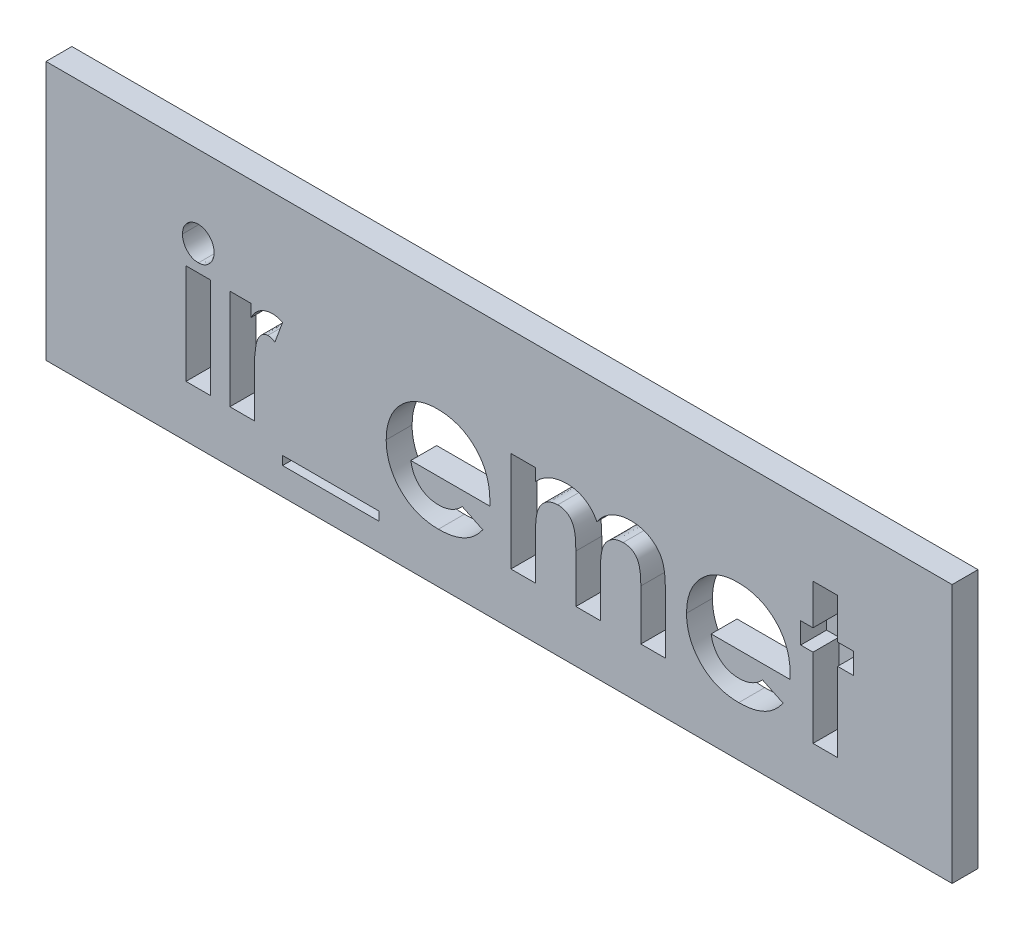
from build123d import *

# Parameters (mm, degrees)
ESQUISSE1_W             = 35
ESQUISSE1_H             = 10
BOSS_EXTRU_1_DEPTH      = 1
ESQUISSE2_R             = 1
BOSS_EXTRU_2_DEPTH      = 3
CHANFREIN1_SIZE         = 0.5
ESQUISSE3_W             = 0.949786325
ESQUISSE3_H             = 3.866987179
ESQUISSE3_W_2           = 3.731303419
ESQUISSE3_H_2           = 0.339209402
ENL_V_MAT_EXTRU_2_DEPTH = 1


with BuildPart() as part:
    # Esquisse1 → Boss.-Extru.1 (new body)
    with BuildSketch(Plane.XY):
        with Locations((17.5, -5)):
            Rectangle(ESQUISSE1_W, ESQUISSE1_H)
    extrude(amount=BOSS_EXTRU_1_DEPTH)

    # Esquisse2 → Boss.-Extru.2 (add)
    with BuildSketch(Plane(origin=(0, 0, 0), x_dir=(-1, 0, 0), z_dir=(0, 0, -1))):
        with Locations(Location((-30, -5, 0), (0, 0, 180))):  # turned: the seam where the file's is
            Circle(ESQUISSE2_R)
        with Locations(Location((-5, -5, 0), (0, 0, 180))):  # turned: the seam where the file's is
            Circle(ESQUISSE2_R)
    extrude(amount=BOSS_EXTRU_2_DEPTH)

    # Chanfrein1
    chanfrein1_edges = [part.edges().sort_by_distance(p)[0] for p in [
        (29, -5, -3),
        (4, -5, -3),
    ]]
    chamfer(chanfrein1_edges, length=CHANFREIN1_SIZE)

    # Esquisse3 → Enlèv. mat.-Extru.2 (cut)
    with BuildSketch(Plane.XY.offset(1)):
        with BuildLine():
            add(Edge.make_bspline(
                [(5.879824386, -2.504807692), (5.92076017, -2.506816157), (6.001141525, -2.51075997), (6.116298756, -2.549203379), (6.221989755, -2.609539161), (6.315423529, -2.692321292), (6.393133006, -2.791178297), (6.452505932, -2.901855287), (6.485580115, -3.024481827), (6.49017363, -3.109190958), (6.492521368, -3.152485644)],
                knots=[0, 0, 0, 0, 0.989868614, 1.943702388, 2.910836514, 3.924849579, 4.949916355, 5.946401046, 6.950409252, 8, 8, 8, 8], degree=3))
            add(Edge.make_bspline(
                [(6.492521368, -3.152485644), (6.490257628, -3.195461271), (6.485846625, -3.279201328), (6.451744709, -3.400163155), (6.394754806, -3.510786389), (6.316415931, -3.608175184), (6.223995101, -3.68962406), (6.120613531, -3.751055201), (6.006559841, -3.787360012), (5.927425761, -3.791633507), (5.887244591, -3.793803419)],
                knots=[0, 0, 0, 0, 1.05296456, 2.051751585, 3.055639087, 4.085634717, 5.099016424, 6.062201612, 7.016062274, 8, 8, 8, 8], degree=3))
            add(Edge.make_bspline(
                [(5.887244591, -3.793803419), (5.845951472, -3.791802134), (5.764870802, -3.787872533), (5.648769045, -3.749339175), (5.541668398, -3.689478577), (5.448639939, -3.605005079), (5.370040515, -3.50544562), (5.313261022, -3.392191974), (5.277744044, -3.268726916), (5.27352821, -3.182763185), (5.271367521, -3.138705262)],
                knots=[0, 0, 0, 0, 0.989065327, 1.942068821, 2.907541208, 3.917690034, 4.939857478, 5.938239964, 6.943311734, 8, 8, 8, 8], degree=3))
            add(Edge.make_bspline(
                [(5.271367521, -3.138705262), (5.273718942, -3.096459386), (5.278337968, -3.013473462), (5.31161027, -2.893573269), (5.369621776, -2.784756933), (5.446771504, -2.687709598), (5.539384615, -2.606471665), (5.645012166, -2.547968321), (5.759394385, -2.511112734), (5.839266553, -2.506931074), (5.879824386, -2.504807692)],
                knots=[0, 0, 0, 0, 1.038616768, 2.040212704, 3.031499824, 4.052181184, 5.074969369, 6.039807101, 7.004644834, 8, 8, 8, 8], degree=3))
        make_face()
        with Locations((5.881944445, -6.066506411)):
            Rectangle(ESQUISSE3_W, ESQUISSE3_H)
        with BuildLine():
            Line((7.103098291, -4.133012821), (7.917200855, -4.133012821))
            Line((7.917200855, -4.133012821), (7.917200855, -4.608966012))
            add(Edge.make_bspline(
                [(7.917200855, -4.608966012), (7.940230253, -4.566667921), (7.985242169, -4.483994547), (8.067932832, -4.373021915), (8.162931215, -4.27956386), (8.266823732, -4.201665623), (8.379925261, -4.140951595), (8.499207145, -4.097685197), (8.623648929, -4.069568033), (8.708538895, -4.066647192), (8.751443977, -4.06517094)],
                knots=[0, 0, 0, 0, 1.09866127, 2.147379032, 3.14564304, 4.131443017, 5.102343063, 6.064490016, 7.021754664, 8, 8, 8, 8], degree=3))
            add(Edge.make_bspline(
                [(8.751443977, -4.06517094), (8.78259842, -4.066629785), (8.84603999, -4.069600514), (8.942733871, -4.086869409), (9.040822874, -4.118094854), (9.105373891, -4.146209218), (9.138354701, -4.160573584)],
                knots=[0, 0, 0, 0, 0.931404136, 1.896671404, 2.925354185, 4, 4, 4, 4], degree=3))
            Line((9.138354701, -4.160573584), (8.843666533, -4.965135884))
            add(Edge.make_bspline(
                [(8.843666533, -4.965135884), (8.817325619, -4.952409228), (8.767814841, -4.928488014), (8.695933787, -4.900258516), (8.630698751, -4.883034257), (8.589340935, -4.880464246), (8.570178953, -4.879273504)],
                knots=[0, 0, 0, 0, 1.214386998, 2.282580073, 3.20428172, 4, 4, 4, 4], degree=3))
            add(Edge.make_bspline(
                [(8.570178953, -4.879273504), (8.552086315, -4.880062553), (8.51649498, -4.881614748), (8.463963165, -4.894916529), (8.414489134, -4.917855038), (8.365688737, -4.947241545), (8.321411784, -4.988090988), (8.277162179, -5.03538147), (8.238167059, -5.093767862), (8.197015897, -5.15875488), (8.161977155, -5.238298932), (8.131932512, -5.333258138), (8.105162494, -5.444731242), (8.086741067, -5.57331011), (8.068936018, -5.717750521), (8.058338015, -5.879112649), (8.05043919, -6.056886251), (8.04995623, -6.180978642), (8.049704527, -6.245651376)],
                knots=[0, 0, 0, 0, 0.544232178, 1.070598461, 1.618251235, 2.182094276, 2.777567932, 3.425210017, 4.127676488, 4.886675562, 5.738955394, 6.734782583, 7.883056018, 9.186093582, 10.642914445, 12.264202625, 14.053029461, 16, 16, 16, 16], degree=3))
            Line((8.049704527, -6.245651376), (8.052884615, -6.434336605))
            Line((8.052884615, -6.434336605), (8.052884615, -8))
            Line((8.052884615, -8), (7.103098291, -8))
            Line((7.103098291, -8), (7.103098291, -4.133012821))
        make_face()
        with Locations((11.004006411, -8.780181624)):
            Rectangle(ESQUISSE3_W_2, ESQUISSE3_H_2)
        with BuildLine():
            Line((17.140516493, -6.303952991), (14.090811966, -6.303952991))
            add(Edge.make_bspline(
                [(14.090811966, -6.303952991), (14.097030067, -6.339388828), (14.109249127, -6.409023042), (14.135783249, -6.510172781), (14.169644768, -6.605494587), (14.210225667, -6.695115884), (14.256841751, -6.779510462), (14.311215552, -6.858282479), (14.372657386, -6.931362358), (14.440812014, -6.998432487), (14.514543421, -7.058528775), (14.593494038, -7.111176923), (14.677745337, -7.154345184), (14.766331408, -7.190731548), (14.859914193, -7.219553234), (14.958631422, -7.239431004), (15.062221412, -7.251172875), (15.132790077, -7.252871202), (15.168861846, -7.253739316)],
                knots=[0, 0, 0, 0, 1.091296461, 2.144483647, 3.168565212, 4.157007626, 5.126487748, 6.090021542, 7.05641414, 8.019231907, 8.98705074, 9.938580405, 10.892824166, 11.854447369, 12.841318655, 13.858982407, 14.905600794, 16, 16, 16, 16], degree=3))
            add(Edge.make_bspline(
                [(15.168861846, -7.253739316), (15.212402919, -7.25258979), (15.298148115, -7.250326034), (15.423765466, -7.23024988), (15.545255743, -7.199925733), (15.66146922, -7.15483118), (15.773752046, -7.098696389), (15.880255704, -7.028759346), (15.982823686, -6.947063841), (16.045402242, -6.884092976), (16.077307025, -6.851988181)],
                knots=[0, 0, 0, 0, 1.021034703, 2.010718019, 2.977989445, 3.954245119, 4.929443971, 5.918328161, 6.938689359, 8, 8, 8, 8], degree=3))
            Line((16.077307025, -6.851988181), (16.87232906, -7.23041867))
            add(Edge.make_bspline(
                [(16.87232906, -7.23041867), (16.847298255, -7.2650074), (16.797700636, -7.333543698), (16.716734187, -7.42999197), (16.632240542, -7.51998212), (16.544156686, -7.602922269), (16.452370906, -7.678576072), (16.357138528, -7.747865128), (16.257067769, -7.808929053), (16.154159528, -7.864722083), (16.046286499, -7.91255319), (15.933747216, -7.953341869), (15.817018344, -7.990214488), (15.694625851, -8.018309404), (15.567588898, -8.04054911), (15.435603588, -8.056342248), (15.298687315, -8.066096912), (15.205626122, -8.067253315), (15.158261552, -8.06784188)],
                knots=[0, 0, 0, 0, 1.028154879, 2.037251081, 3.030720504, 4.000128189, 4.949298328, 5.894184978, 6.834267904, 7.770992897, 8.712077017, 9.673380525, 10.653304757, 11.658697181, 12.695551717, 13.758623199, 14.859225354, 16, 16, 16, 16], degree=3))
            add(Edge.make_bspline(
                [(15.158261552, -8.06784188), (15.085391938, -8.066356288), (14.942680999, -8.063446841), (14.733940453, -8.036443012), (14.53569483, -7.991667753), (14.347384355, -7.930802664), (14.16982303, -7.85044168), (14.00292298, -7.752153529), (13.845016634, -7.637822594), (13.700928914, -7.505049371), (13.56966075, -7.360533612), (13.454362956, -7.205333555), (13.357883404, -7.040533524), (13.278652456, -6.867224201), (13.217071411, -6.684961981), (13.172675049, -6.49366733), (13.145459547, -6.293431612), (13.142520138, -6.157048736), (13.141025641, -6.087706998)],
                knots=[0, 0, 0, 0, 1.103565453, 2.161269334, 3.182010356, 4.179077853, 5.15417608, 6.128274628, 7.109042802, 8.101804412, 9.090965879, 10.063106201, 11.02526161, 11.978650795, 12.945248442, 13.93468508, 14.949922959, 16, 16, 16, 16], degree=3))
            add(Edge.make_bspline(
                [(13.141025641, -6.087706998), (13.142534847, -6.016603197), (13.145504141, -5.876709662), (13.172440723, -5.67185041), (13.217194151, -5.476386975), (13.278955335, -5.290050184), (13.35698434, -5.112257255), (13.454691429, -4.944563662), (13.569603534, -4.786385588), (13.700398807, -4.638463007), (13.845096927, -4.504946716), (13.998852351, -4.385957019), (14.163392677, -4.286806905), (14.336856814, -4.206693674), (14.518135222, -4.141603697), (14.709323225, -4.098291753), (14.908966176, -4.069210375), (15.045437701, -4.066532162), (15.114800347, -4.06517094)],
                knots=[0, 0, 0, 0, 1.079208495, 2.12329425, 3.130605359, 4.119693003, 5.099659317, 6.073216462, 7.060498243, 8.06384408, 9.066070512, 10.045757761, 11.010926815, 11.975797609, 12.942977511, 13.929384301, 14.947594487, 16, 16, 16, 16], degree=3))
            add(Edge.make_bspline(
                [(15.114800347, -4.06517094), (15.188019056, -4.06667958), (15.331776445, -4.06964164), (15.541970805, -4.096426204), (15.741532754, -4.141474498), (15.93131254, -4.201813297), (16.108886594, -4.284204284), (16.27815676, -4.380073719), (16.435062976, -4.496876004), (16.581277698, -4.628999478), (16.713266367, -4.775585892), (16.828639088, -4.934823635), (16.926807074, -5.105158639), (17.0063732, -5.287281648), (17.067891013, -5.480645912), (17.112328472, -5.68500031), (17.139336384, -5.901122106), (17.142221098, -6.049113087), (17.143696581, -6.124808026)],
                knots=[0, 0, 0, 0, 1.080001299, 2.120471247, 3.119684163, 4.095710327, 5.052285597, 6.002875087, 6.961153713, 7.931888285, 8.906493152, 9.865905668, 10.82813294, 11.801621613, 12.7925306, 13.817193356, 14.883530496, 16, 16, 16, 16], degree=3))
            Line((17.143696581, -6.124808026), (17.140516493, -6.303952991))
        make_face()
        with BuildLine():
            Line((17.957799145, -4.133012821), (18.90758547, -4.133012821))
            Line((18.90758547, -4.133012821), (18.90758547, -4.59518563))
            add(Edge.make_bspline(
                [(18.90758547, -4.59518563), (18.949831483, -4.552547263), (19.033010411, -4.468595821), (19.170854165, -4.360668696), (19.314639159, -4.268377671), (19.466107838, -4.193662277), (19.624889717, -4.136611678), (19.790232251, -4.09480584), (19.962984709, -4.070141705), (20.080605785, -4.066846229), (20.140399639, -4.06517094)],
                knots=[0, 0, 0, 0, 1.041528618, 2.050684245, 3.032913108, 4.004406485, 4.976926473, 5.95771665, 6.961784757, 8, 8, 8, 8], degree=3))
            add(Edge.make_bspline(
                [(20.140399639, -4.06517094), (20.200272443, -4.067054206), (20.31813012, -4.070761355), (20.49008365, -4.104685241), (20.652982147, -4.159800091), (20.805033343, -4.238359539), (20.947336177, -4.335376374), (21.073586538, -4.45586279), (21.187227035, -4.595022486), (21.247801795, -4.700228713), (21.278871194, -4.754190037)],
                knots=[0, 0, 0, 0, 1.023965777, 2.015643508, 2.987309376, 3.958410333, 4.93654923, 5.924956801, 6.93568961, 8, 8, 8, 8], degree=3))
            add(Edge.make_bspline(
                [(21.278871194, -4.754190037), (21.318892595, -4.700081917), (21.397443375, -4.593882862), (21.536681787, -4.455227954), (21.687240052, -4.33536381), (21.852031126, -4.237643293), (22.02667873, -4.160068241), (22.210418627, -4.104890023), (22.40158497, -4.070818051), (22.531684157, -4.067068949), (22.597547743, -4.06517094)],
                knots=[0, 0, 0, 0, 1.041189987, 2.043563759, 3.033412161, 4.015238574, 5.00275396, 5.986226558, 6.980513695, 8, 8, 8, 8], degree=3))
            add(Edge.make_bspline(
                [(22.597547743, -4.06517094), (22.665577006, -4.067141729), (22.798057671, -4.070979658), (22.990041178, -4.108738156), (23.169856965, -4.167080701), (23.333531152, -4.251983383), (23.481530555, -4.352553973), (23.607643899, -4.471382321), (23.712306452, -4.604321999), (23.780455196, -4.728455222), (23.824511527, -4.838203205), (23.851113132, -4.933704514), (23.875993863, -5.040343805), (23.893868178, -5.159554459), (23.910553062, -5.290215988), (23.920239294, -5.433197075), (23.926823126, -5.588016049), (23.927522412, -5.695134454), (23.927884615, -5.750617655)],
                knots=[0, 0, 0, 0, 1.321991808, 2.574456155, 3.791773975, 4.987670122, 6.148905103, 7.262530793, 8.344737981, 9.427709016, 10.004683293, 10.642050061, 11.354108788, 12.133887687, 12.985666279, 13.916212488, 14.92067847, 16, 16, 16, 16], degree=3))
            Line((23.927884615, -5.750617655), (23.927884615, -8))
            Line((23.927884615, -8), (22.978098291, -8))
            Line((22.978098291, -8), (22.978098291, -6.058026175))
            add(Edge.make_bspline(
                [(22.978098291, -6.058026175), (22.977307773, -6.006081985), (22.975790447, -5.906379806), (22.969339708, -5.763376066), (22.954900195, -5.633684014), (22.937975235, -5.516585277), (22.913755291, -5.412700728), (22.884223467, -5.321779938), (22.849966731, -5.243692031), (22.808602754, -5.178445146), (22.762275052, -5.123496962), (22.710742167, -5.076395486), (22.654541407, -5.036208607), (22.59316323, -5.001955004), (22.524999686, -4.978788614), (22.452351868, -4.960611438), (22.374651285, -4.948232651), (22.32092912, -4.947494664), (22.293319311, -4.947115385)],
                knots=[0, 0, 0, 0, 1.669139205, 3.203761885, 4.596586177, 5.860166715, 7.002923539, 8.018877315, 8.928339525, 9.734594377, 10.491888885, 11.231098709, 11.971440889, 12.708030942, 13.480072485, 14.275788656, 15.113863979, 16, 16, 16, 16], degree=3))
            add(Edge.make_bspline(
                [(22.293319311, -4.947115385), (22.250772986, -4.948586321), (22.16728429, -4.951472742), (22.045624244, -4.979055723), (21.931141244, -5.024150945), (21.824264191, -5.085499), (21.727292842, -5.162121562), (21.642467458, -5.253003227), (21.572413521, -5.358667753), (21.523920478, -5.456703237), (21.493618418, -5.545347015), (21.472243068, -5.621263291), (21.455581833, -5.707113371), (21.442540964, -5.802027791), (21.430029772, -5.906543112), (21.423891852, -6.02052717), (21.417610887, -6.143821616), (21.417692652, -6.229033939), (21.417735043, -6.273212139)],
                knots=[0, 0, 0, 0, 1.129913425, 2.217230253, 3.297175357, 4.391411011, 5.481605898, 6.571841268, 7.681894157, 8.841607612, 9.468549532, 10.170608623, 10.93710061, 11.791434153, 12.717934886, 13.734733707, 14.825576123, 16, 16, 16, 16], degree=3))
            Line((21.417735043, -6.273212139), (21.417735043, -8))
            Line((21.417735043, -8), (20.467948718, -8))
            Line((20.467948718, -8), (20.467948718, -6.146008614))
            add(Edge.make_bspline(
                [(20.467948718, -6.146008614), (20.467868974, -6.104662165), (20.467715571, -6.02512499), (20.463104606, -5.910271787), (20.456998786, -5.804220605), (20.448439138, -5.706675648), (20.438567269, -5.617758237), (20.424319888, -5.537954814), (20.4093517, -5.466825637), (20.383688538, -5.386025014), (20.347525843, -5.296484401), (20.293498249, -5.201531568), (20.228171508, -5.122030947), (20.15319675, -5.057363855), (20.068472057, -5.00809272), (19.976143769, -4.971441119), (19.874448934, -4.95165771), (19.804449008, -4.948661445), (19.768329327, -4.947115385)],
                knots=[0, 0, 0, 0, 1.256487322, 2.417074606, 3.49288742, 4.484586665, 5.393016842, 6.210437544, 6.947749329, 7.599905853, 8.784490193, 9.876739139, 10.906602197, 11.896672079, 12.869113195, 13.872201355, 14.902064413, 16, 16, 16, 16], degree=3))
            add(Edge.make_bspline(
                [(19.768329327, -4.947115385), (19.727517195, -4.948500619), (19.646688426, -4.951244088), (19.528948977, -4.980711182), (19.416379144, -5.024978991), (19.31145535, -5.088038137), (19.215944879, -5.166463861), (19.131968779, -5.259930578), (19.062283002, -5.36832742), (19.013574707, -5.469067075), (18.983714487, -5.559922392), (18.961764385, -5.637809906), (18.945723053, -5.725550598), (18.93233904, -5.822159294), (18.91990192, -5.927750032), (18.913738603, -6.042787158), (18.907463844, -6.167143162), (18.907543951, -6.253061473), (18.90758547, -6.297592815)],
                knots=[0, 0, 0, 0, 1.07893236, 2.136834559, 3.195274846, 4.273923004, 5.364443877, 6.458052972, 7.587287137, 8.767908, 9.410170275, 10.118584836, 10.909717261, 11.770069756, 12.702352573, 13.724628867, 14.820678298, 16, 16, 16, 16], degree=3))
            Line((18.90758547, -6.297592815), (18.90758547, -8))
            Line((18.90758547, -8), (17.957799145, -8))
            Line((17.957799145, -8), (17.957799145, -4.133012821))
        make_face()
        with BuildLine():
            Line((28.741478032, -6.303952991), (25.691773504, -6.303952991))
            add(Edge.make_bspline(
                [(25.691773504, -6.303952991), (25.697991606, -6.339388828), (25.710210665, -6.409023042), (25.736744787, -6.510172781), (25.770606307, -6.605494587), (25.811187206, -6.695115884), (25.85780329, -6.779510462), (25.91217709, -6.858282479), (25.973618925, -6.931362358), (26.041773552, -6.998432487), (26.11550496, -7.058528775), (26.194455577, -7.111176923), (26.278706875, -7.154345184), (26.367292946, -7.190731548), (26.460875731, -7.219553234), (26.559592961, -7.239431004), (26.66318295, -7.251172875), (26.733751615, -7.252871202), (26.769823384, -7.253739316)],
                knots=[0, 0, 0, 0, 1.091296461, 2.144483647, 3.168565212, 4.157007626, 5.126487748, 6.090021542, 7.05641414, 8.019231907, 8.98705074, 9.938580405, 10.892824166, 11.854447369, 12.841318655, 13.858982407, 14.905600794, 16, 16, 16, 16], degree=3))
            add(Edge.make_bspline(
                [(26.769823384, -7.253739316), (26.813364458, -7.25258979), (26.899109654, -7.250326034), (27.024727005, -7.23024988), (27.146217282, -7.199925733), (27.262430758, -7.15483118), (27.374713585, -7.098696389), (27.481217242, -7.028759346), (27.583785224, -6.947063841), (27.64636378, -6.884092976), (27.678268563, -6.851988181)],
                knots=[0, 0, 0, 0, 1.021034703, 2.010718019, 2.977989445, 3.954245119, 4.929443971, 5.918328161, 6.938689359, 8, 8, 8, 8], degree=3))
            Line((27.678268563, -6.851988181), (28.473290598, -7.23041867))
            add(Edge.make_bspline(
                [(28.473290598, -7.23041867), (28.448259794, -7.2650074), (28.398662174, -7.333543698), (28.317695726, -7.42999197), (28.23320208, -7.51998212), (28.145118224, -7.602922269), (28.053332444, -7.678576072), (27.958100066, -7.747865128), (27.858029308, -7.808929053), (27.755121066, -7.864722083), (27.647248038, -7.91255319), (27.534708754, -7.953341869), (27.417979882, -7.990214488), (27.29558739, -8.018309404), (27.168550437, -8.04054911), (27.036565126, -8.056342248), (26.899648854, -8.066096912), (26.806587661, -8.067253315), (26.75922309, -8.06784188)],
                knots=[0, 0, 0, 0, 1.028154879, 2.037251081, 3.030720504, 4.000128189, 4.949298328, 5.894184978, 6.834267904, 7.770992897, 8.712077017, 9.673380525, 10.653304757, 11.658697181, 12.695551717, 13.758623199, 14.859225354, 16, 16, 16, 16], degree=3))
            add(Edge.make_bspline(
                [(26.75922309, -8.06784188), (26.686353476, -8.066356288), (26.543642538, -8.063446841), (26.334901991, -8.036443012), (26.136656369, -7.991667753), (25.948345893, -7.930802664), (25.770784568, -7.85044168), (25.603884518, -7.752153529), (25.445978173, -7.637822594), (25.301890452, -7.505049371), (25.170622288, -7.360533612), (25.055324495, -7.205333555), (24.958844943, -7.040533524), (24.879613995, -6.867224201), (24.818032949, -6.684961981), (24.773636587, -6.49366733), (24.746421085, -6.293431612), (24.743481676, -6.157048736), (24.741987179, -6.087706998)],
                knots=[0, 0, 0, 0, 1.103565453, 2.161269334, 3.182010356, 4.179077853, 5.15417608, 6.128274628, 7.109042802, 8.101804412, 9.090965879, 10.063106201, 11.02526161, 11.978650795, 12.945248442, 13.93468508, 14.949922959, 16, 16, 16, 16], degree=3))
            add(Edge.make_bspline(
                [(24.741987179, -6.087706998), (24.743496385, -6.016603197), (24.746465679, -5.876709662), (24.773402262, -5.67185041), (24.81815569, -5.476386975), (24.879916873, -5.290050184), (24.957945878, -5.112257255), (25.055652967, -4.944563662), (25.170565072, -4.786385588), (25.301360346, -4.638463007), (25.446058466, -4.504946716), (25.599813889, -4.385957019), (25.764354216, -4.286806905), (25.937818352, -4.206693674), (26.11909676, -4.141603697), (26.310284764, -4.098291753), (26.509927714, -4.069210375), (26.646399239, -4.066532162), (26.715761886, -4.06517094)],
                knots=[0, 0, 0, 0, 1.079208495, 2.12329425, 3.130605359, 4.119693003, 5.099659317, 6.073216462, 7.060498243, 8.06384408, 9.066070512, 10.045757761, 11.010926815, 11.975797609, 12.942977511, 13.929384301, 14.947594487, 16, 16, 16, 16], degree=3))
            add(Edge.make_bspline(
                [(26.715761886, -4.06517094), (26.788980594, -4.06667958), (26.932737983, -4.06964164), (27.142932343, -4.096426204), (27.342494293, -4.141474498), (27.532274078, -4.201813297), (27.709848133, -4.284204284), (27.879118298, -4.380073719), (28.036024515, -4.496876004), (28.182239237, -4.628999478), (28.314227905, -4.775585892), (28.429600626, -4.934823635), (28.527768612, -5.105158639), (28.607334739, -5.287281648), (28.668852552, -5.480645912), (28.713290011, -5.68500031), (28.740297923, -5.901122106), (28.743182636, -6.049113087), (28.74465812, -6.124808026)],
                knots=[0, 0, 0, 0, 1.080001299, 2.120471247, 3.119684163, 4.095710327, 5.052285597, 6.002875087, 6.961153713, 7.931888285, 8.906493152, 9.865905668, 10.82813294, 11.801621613, 12.7925306, 13.817193356, 14.883530496, 16, 16, 16, 16], degree=3))
            Line((28.74465812, -6.124808026), (28.741478032, -6.303952991))
        make_face()
        Polygon((29.626602564, -2.572649573), (30.576388889, -2.572649573), (30.576388889, -4.133012821), (31.186965812, -4.133012821), (31.186965812, -4.947115385), (30.576388889, -4.947115385), (30.576388889, -8), (29.626602564, -8), (29.626602564, -4.947115385), (29.151709402, -4.947115385), (29.151709402, -4.133012821), (29.626602564, -4.133012821), align=None)
    extrude(amount=-ENL_V_MAT_EXTRU_2_DEPTH, mode=Mode.SUBTRACT)


solid = part.part
